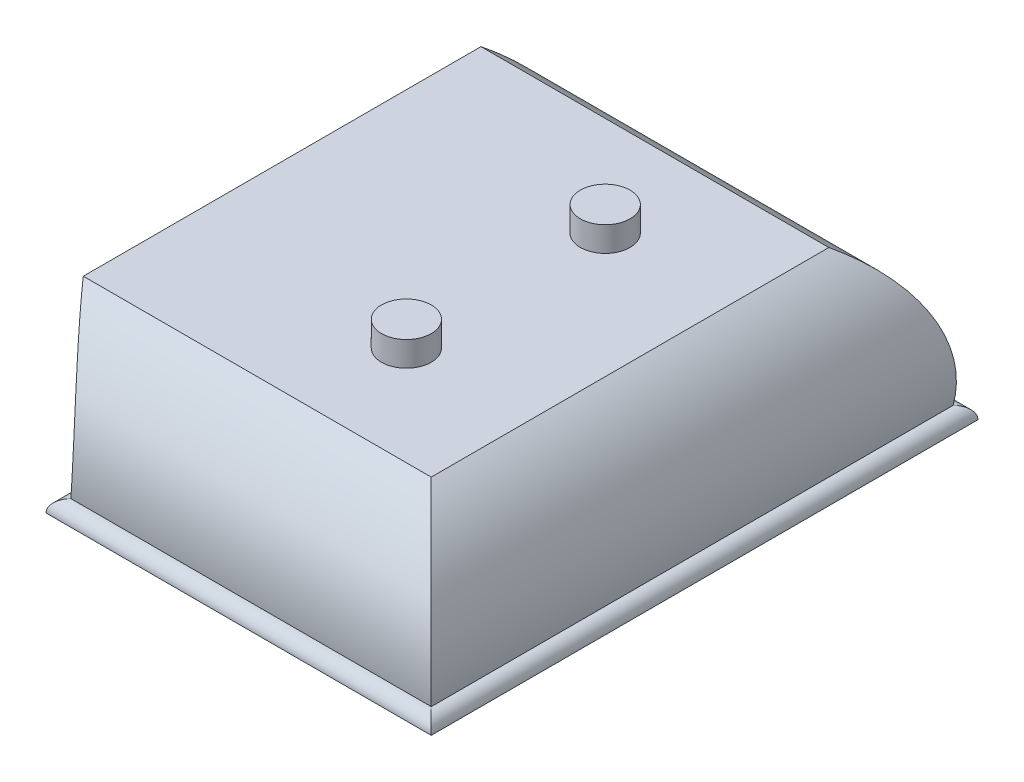
from build123d import *

# Parameters (mm, degrees)
SKETCH1_W               = 228.6
SKETCH1_H               = 101.6
BOSS_EXTRUDE1_DEPTH     = 38.1
SKETCH2_W               = 266.7
SKETCH2_H               = 139.7
BOSS_EXTRUDE2_DEPTH     = 38.1
CUT_EXTRUDE1_DEPTH      = 70.85
CUT_EXTRUDE1_DEPTH_BACK = 70.85
CUT_EXTRUDE2_DEPTH      = 134.35
CUT_EXTRUDE2_DEPTH_BACK = 134.35
BOSS_EXTRUDE3_DEPTH     = 117.475
CUT_EXTRUDE3_DEPTH      = 70.85
CUT_EXTRUDE3_DEPTH_BACK = 70.85
BOSS_EXTRUDE6_DEPTH     = 50.8
CUT_EXTRUDE4_DEPTH      = 134.35
CUT_EXTRUDE4_DEPTH_BACK = 134.35
BOSS_EXTRUDE7_DEPTH     = 11.43
SKETCH12_W              = 101.6
SKETCH12_H              = 44.45
CUT_EXTRUDE5_DEPTH      = 57.15
SKETCH13_W              = 25.4
SKETCH13_H              = 15.875
CUT_EXTRUDE6_DEPTH      = 8.89
SKETCH14_W              = 234.95
SKETCH14_H              = 73.385904338
CUT_EXTRUDE7_DEPTH      = 70.85
CUT_EXTRUDE7_DEPTH_BACK = 70.85
SKETCH15_R              = 6.35
BOSS_EXTRUDE8_DEPTH     = 6.35
SKETCH16_W              = 114.519931472
SKETCH16_H              = 54.078527613
CUT_EXTRUDE8_DEPTH      = 70.85
CUT_EXTRUDE8_DEPTH_BACK = 70.85


with BuildPart() as part:
    # Sketch1 → Boss-Extrude1 (new body)
    with BuildSketch(Plane(origin=(0, 0, 0), x_dir=(1, 0, 0), z_dir=(0, 1, 0))):
        Rectangle(SKETCH1_W, SKETCH1_H)
    extrude(amount=BOSS_EXTRUDE1_DEPTH)

    # Sketch2 → Boss-Extrude2 (add)
    with BuildSketch(Plane.XZ):
        Rectangle(SKETCH2_W, SKETCH2_H)
    extrude(amount=BOSS_EXTRUDE2_DEPTH)

    # Sketch4 → Cut-Extrude1 (cut, two sides)
    with BuildSketch(Plane.XY) as cut_extrude1_sk:
        with BuildLine():
            Line((25.4, 0), (-25.4, 0))
            ThreePointArc((-25.4, 0), (-36.780856653, -15.633097581), (-38.1, -34.925))
            ThreePointArc((-38.1, -34.925), (-35.85493597, -35.85493597), (-34.925, -38.1))
            Line((-34.925, -38.1), (34.925, -38.1))
            ThreePointArc((34.925, -38.1), (35.85493597, -35.85493597), (38.1, -34.925))
            ThreePointArc((38.1, -34.925), (36.780856653, -15.633097581), (25.4, 0))
        make_face()
        with BuildLine():
            Line((114.3, 0), (138.625991559, 8.381745969))
            Line((138.625991559, 8.381745969), (149.850712343, -24.19529276))
            Line((149.850712343, -24.19529276), (133.35, -38.1))
            ThreePointArc((133.35, -38.1), (132.42006403, -35.85493597), (130.175, -34.925))
            ThreePointArc((130.175, -34.925), (127.462245798, -15.087615547), (114.3, 0))
        make_face()
        with BuildLine():
            Line((-149.850712343, -24.19529276), (-133.35, -38.1))
            ThreePointArc((-133.35, -38.1), (-132.42006403, -35.85493597), (-130.175, -34.925))
            ThreePointArc((-130.175, -34.925), (-127.462245798, -15.087615547), (-114.3, 0))
            Line((-114.3, 0), (-138.625991559, 8.381745969))
            Line((-138.625991559, 8.381745969), (-149.850712343, -24.19529276))
        make_face()
    extrude(amount=CUT_EXTRUDE1_DEPTH, mode=Mode.SUBTRACT)
    extrude(cut_extrude1_sk.sketch, amount=-CUT_EXTRUDE1_DEPTH_BACK, mode=Mode.SUBTRACT)

    # Sketch5 → Cut-Extrude2 (cut, two sides)
    with BuildSketch(Plane(origin=(0, 0, 0), x_dir=(0, 0, -1), z_dir=(1, 0, 0))) as cut_extrude2_sk:
        with BuildLine():
            Line((-69.85, -38.1), (-80.267672211, -6.179959038))
            Line((-80.267672211, -6.179959038), (-69.85, 0.848763613))
            Line((-69.85, 0.848763613), (-50.8, 0))
            ThreePointArc((-50.8, 0), (-63.962245798, -15.087615547), (-66.675, -34.925))
            ThreePointArc((-66.675, -34.925), (-68.92006403, -35.85493597), (-69.85, -38.1))
        make_face()
        with BuildLine():
            Line((69.85, 0.848763613), (50.8, 0))
            ThreePointArc((50.8, 0), (63.962245798, -15.087615547), (66.675, -34.925))
            ThreePointArc((66.675, -34.925), (68.92006403, -35.85493597), (69.85, -38.1))
            Line((69.85, -38.1), (80.267672211, -6.179959038))
            Line((80.267672211, -6.179959038), (69.85, 0.848763613))
        make_face()
    extrude(amount=CUT_EXTRUDE2_DEPTH, mode=Mode.SUBTRACT)
    extrude(cut_extrude2_sk.sketch, amount=-CUT_EXTRUDE2_DEPTH_BACK, mode=Mode.SUBTRACT)

    # Sketch7 → Boss-Extrude3 (add, symmetric)
    with BuildSketch(Plane(origin=(0, 0, 0), x_dir=(0, 0, -1), z_dir=(1, 0, 0))):
        with BuildLine():
            Line((-50.8, 38.1), (50.8, 38.1))
            ThreePointArc((50.8, 38.1), (53.975, 34.925), (50.8, 31.75))
            ThreePointArc((50.8, 31.75), (52.363441445, 19.05), (50.8, 6.35))
            ThreePointArc((50.8, 6.35), (53.975, 3.175), (50.8, 0))
            Line((50.8, 0), (-50.8, 0))
            ThreePointArc((-50.8, 0), (-53.975, 3.175), (-50.8, 6.35))
            ThreePointArc((-50.8, 6.35), (-52.363441445, 19.05), (-50.8, 31.75))
            ThreePointArc((-50.8, 31.75), (-53.975, 34.925), (-50.8, 38.1))
        make_face()
    extrude(amount=BOSS_EXTRUDE3_DEPTH, both=True)

    # Sketch8 → Cut-Extrude3 (cut, two sides)
    with BuildSketch(Plane.XY) as cut_extrude3_sk:
        with BuildLine():
            Line((-114.3, 38.1), (-123.468271352, 41.287608438))
            Line((-123.468271352, 41.287608438), (-120.491237125, -2.317187004))
            Line((-120.491237125, -2.317187004), (-114.3, 0))
            ThreePointArc((-114.3, 0), (-117.475, 3.175), (-114.3, 6.35))
            ThreePointArc((-114.3, 6.35), (-116.592108499, 19.05), (-114.3, 31.75))
            ThreePointArc((-114.3, 31.75), (-117.475, 34.925), (-114.3, 38.1))
        make_face()
        with BuildLine():
            Line((120.491237125, -2.317187004), (114.3, 0))
            ThreePointArc((114.3, 0), (117.475, 3.175), (114.3, 6.35))
            ThreePointArc((114.3, 6.35), (116.592108499, 19.05), (114.3, 31.75))
            ThreePointArc((114.3, 31.75), (117.475, 34.925), (114.3, 38.1))
            Line((114.3, 38.1), (123.468271352, 41.287608438))
            Line((123.468271352, 41.287608438), (120.491237125, -2.317187004))
        make_face()
    extrude(amount=CUT_EXTRUDE3_DEPTH, mode=Mode.SUBTRACT)
    extrude(cut_extrude3_sk.sketch, amount=-CUT_EXTRUDE3_DEPTH_BACK, mode=Mode.SUBTRACT)

    # Sketch9 → Boss-Extrude6 (add, symmetric)
    with BuildSketch(Plane.XY):
        with BuildLine():
            Line((-114.3, 38.1), (114.3, 38.1))
            ThreePointArc((114.3, 38.1), (92.707665567, 45.121477655), (79.375, 63.5))
            ThreePointArc((79.375, 63.5), (0, 41.272917837), (-79.375, 63.5))
            ThreePointArc((-79.375, 63.5), (-92.707665567, 45.121477655), (-114.3, 38.1))
        make_face()
    extrude(amount=BOSS_EXTRUDE6_DEPTH, both=True)

    # Sketch10 → Cut-Extrude4 (cut, two sides)
    with BuildSketch(Plane(origin=(0, 0, 0), x_dir=(0, 0, -1), z_dir=(1, 0, 0))) as cut_extrude4_sk:
        with BuildLine():
            Line((25.4, 63.5), (50.8, 63.5))
            Line((50.8, 63.5), (50.8, 38.1))
            ThreePointArc((50.8, 38.1), (35.780017166, 48.480017166), (25.4, 63.5))
        make_face()
        with BuildLine():
            Line((-50.8, 63.5), (-50.8, 38.1))
            ThreePointArc((-50.8, 38.1), (-35.780017166, 48.480017166), (-25.4, 63.5))
            Line((-25.4, 63.5), (-50.8, 63.5))
        make_face()
    extrude(amount=CUT_EXTRUDE4_DEPTH, mode=Mode.SUBTRACT)
    extrude(cut_extrude4_sk.sketch, amount=-CUT_EXTRUDE4_DEPTH_BACK, mode=Mode.SUBTRACT)

    # Sketch11 → Boss-Extrude7 (add)
    with BuildSketch(Plane.XY.offset(9.525)):
        with BuildLine():
            Line((-79.375, 63.5), (-79.375, 68.58))
            ThreePointArc((-79.375, 68.58), (0, 45.590721784), (79.375, 68.58))
            Line((79.375, 68.58), (79.375, 63.5))
            ThreePointArc((79.375, 63.5), (0, 23.789706403), (-79.375, 63.5))
        make_face()
    extrude(amount=BOSS_EXTRUDE7_DEPTH)

    # Sketch12 → Cut-Extrude5 (cut)
    with BuildSketch(Plane(origin=(0, 63.5, 0), x_dir=(-1, 0, 0), z_dir=(0, -1, 0))):
        Rectangle(SKETCH12_W, SKETCH12_H)
    extrude(amount=CUT_EXTRUDE5_DEPTH, mode=Mode.SUBTRACT)

    # Sketch13 → Cut-Extrude6 (cut)
    with BuildSketch(Plane.XY.offset(-22.225)):
        with Locations((-6.35, 26.9875)):
            Rectangle(SKETCH13_W, SKETCH13_H)
    extrude(amount=-CUT_EXTRUDE6_DEPTH, mode=Mode.SUBTRACT)

    # Sketch14 → Cut-Extrude7 (cut, two sides)
    with BuildSketch(Plane.XY) as cut_extrude7_sk:
        with Locations((0, 36.692952169)):
            Rectangle(SKETCH14_W, SKETCH14_H)
    extrude(amount=CUT_EXTRUDE7_DEPTH, mode=Mode.SUBTRACT)
    extrude(cut_extrude7_sk.sketch, amount=-CUT_EXTRUDE7_DEPTH_BACK, mode=Mode.SUBTRACT)

    # Sketch15 → Boss-Extrude8 (add)
    with BuildSketch(Plane(origin=(0, 0, 0), x_dir=(1, 0, 0), z_dir=(0, 1, 0))):
        with Locations(Location((-82.55, 25.4, 0), (0, 0, 90))):  # turned: the seam where the file's is
            Circle(SKETCH15_R)
        with Locations(Location((-82.55, -25.4, 0), (0, 0, 90))):  # turned: the seam where the file's is
            Circle(SKETCH15_R)
        with Locations(Location((82.55, -25.4, 0), (0, 0, 90))):  # turned: the seam where the file's is
            Circle(SKETCH15_R)
        with Locations(Location((82.55, 25.4, 0), (0, 0, 90))):  # turned: the seam where the file's is
            Circle(SKETCH15_R)
    extrude(amount=BOSS_EXTRUDE8_DEPTH)

    # Sketch16 → Cut-Extrude8 (cut, two sides)
    with BuildSketch(Plane.XY) as cut_extrude8_sk:
        with Locations((-80.803403424, -19.002671916)):
            Rectangle(SKETCH16_W, SKETCH16_H)
    extrude(amount=CUT_EXTRUDE8_DEPTH, mode=Mode.SUBTRACT)
    extrude(cut_extrude8_sk.sketch, amount=-CUT_EXTRUDE8_DEPTH_BACK, mode=Mode.SUBTRACT)


solid = part.part
